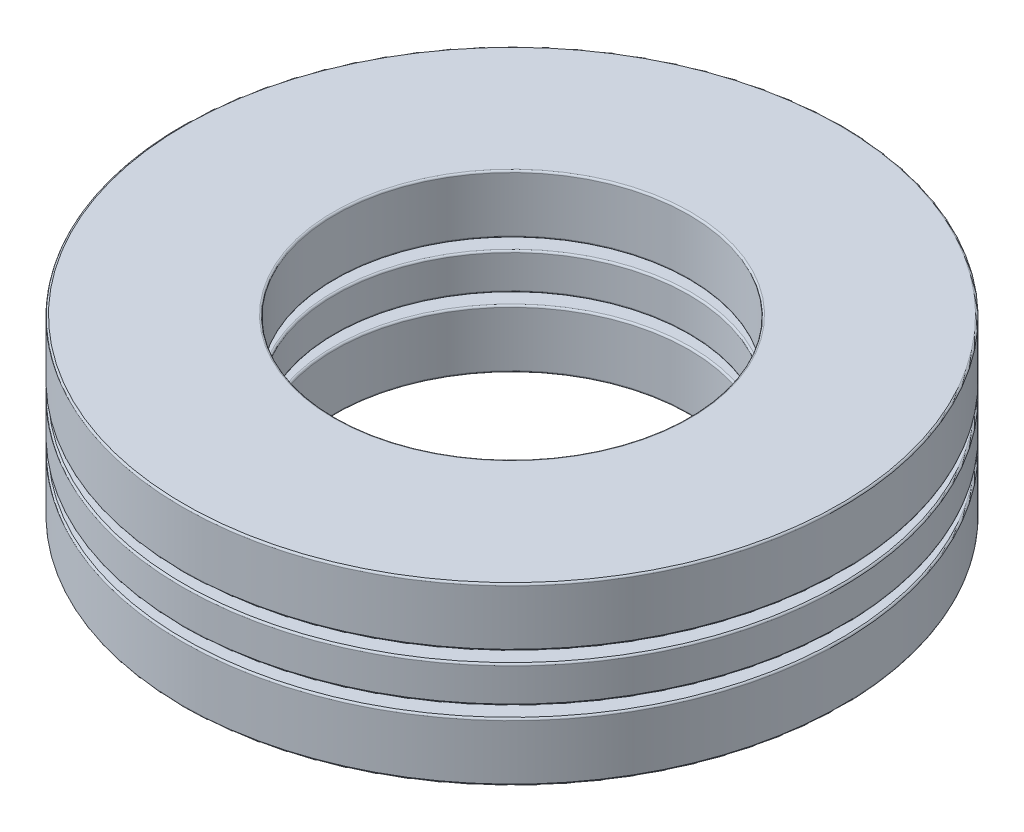
from build123d import *

# Parameters (mm, degrees)
SKETCH1_W         = 5.51815
SKETCH1_H         = 1.317625
CIRPATTERN1_COUNT = 5
CIRPATTERN1_ANGLE = 288
CIRPATTERN2_COUNT = 5
SKETCH4_W         = 5.51815
SKETCH4_H         = 2.1082
FILLET1_R         = 0.063246
FILLET2_R         = 0.063246
FILLET3_R         = 0.063246


with BuildPart() as part:
    # Sketch1 → Revolve1 (revolve)
    with BuildSketch(Plane(origin=(0, 0, 0), x_dir=(0, 0, -1), z_dir=(1, 0, 0))):
        with Locations((-9.147175, 0)):
            Rectangle(SKETCH1_W, SKETCH1_H)
    revolve(axis=Axis((0, -3.1623, 0), (0, 1, 0)))

    # Sketch3 → Cut-Revolve1 (revolve, cut)
    with BuildSketch(Plane(origin=(0, 0, 0), x_dir=(0, 0, -1), z_dir=(1, 0, 0))):
        with BuildLine():
            Line((-9.147175, 1.0541), (-9.147175, -1.0541))
            ThreePointArc((-9.147175, -1.0541), (-10.201275, 0), (-9.147175, 1.0541))
        make_face()
    cut_revolve1 = revolve(axis=Axis((0, 1.0541, 9.147175), (0, -1, 0)), mode=Mode.SUBTRACT)

    # CirPattern2: Cut-Revolve1 ×5 about axis
    cirpattern2_axis = Axis((0, 0, 0), (0, 1, 0))
    for i in range(1, CIRPATTERN2_COUNT):
        add(cut_revolve1.rotate(cirpattern2_axis, i * 360 / CIRPATTERN2_COUNT), mode=Mode.SUBTRACT)

    # Fillet2
    fillet2_edges = [part.edges().sort_by_distance(p)[0] for p in [
        (0, 0.6588125, -11.90625),
        (0, 0.6588125, -6.3881),
        (0, -0.6588125, -6.3881),
        (0, -0.6588125, -11.90625),
    ]]
    fillet(fillet2_edges, radius=FILLET2_R)


with BuildPart() as body_2:
    # Sketch2 → Revolve2 (revolve)
    with BuildSketch(Plane(origin=(0, 0, 0), x_dir=(0, 0, -1), z_dir=(1, 0, 0))):
        with BuildLine():
            Line((-9.147175, 1.0541), (-9.147175, -1.0541))
            ThreePointArc((-9.147175, -1.0541), (-10.201275, 0), (-9.147175, 1.0541))
        make_face()
    revolve(axis=Axis((0, 1.0541, 9.147175), (0, -1, 0)))


with BuildPart() as cirpattern1_1:
    # CirPattern1: pattern copy
    add(body_2.part.rotate(Axis((0, 3.1623, 0), (0, -1, 0)), 1 * CIRPATTERN1_ANGLE / (CIRPATTERN1_COUNT - 1)))


with BuildPart() as cirpattern1_2:
    # CirPattern1: pattern copy
    add(body_2.part.rotate(Axis((0, 3.1623, 0), (0, -1, 0)), 2 * CIRPATTERN1_ANGLE / (CIRPATTERN1_COUNT - 1)))


with BuildPart() as cirpattern1_3:
    # CirPattern1: pattern copy
    add(body_2.part.rotate(Axis((0, 3.1623, 0), (0, -1, 0)), 3 * CIRPATTERN1_ANGLE / (CIRPATTERN1_COUNT - 1)))


with BuildPart() as cirpattern1_4:
    # CirPattern1: pattern copy
    add(body_2.part.rotate(Axis((0, 3.1623, 0), (0, -1, 0)), 4 * CIRPATTERN1_ANGLE / (CIRPATTERN1_COUNT - 1)))


with BuildPart() as body_7:
    # Sketch4 → Revolve3 (revolve)
    with BuildSketch(Plane(origin=(0, 0, 0), x_dir=(0, 0, -1), z_dir=(1, 0, 0))):
        with Locations((-9.147175, 2.1082)):
            Rectangle(SKETCH4_W, SKETCH4_H)
        with Locations((-9.147175, -2.1082)):
            Rectangle(SKETCH4_W, SKETCH4_H)
    revolve(axis=Axis((0, -3.1623, 0), (0, 1, 0)))

    # Fillet1
    fillet1_edges = [body_7.edges().sort_by_distance(p)[0] for p in [
        (0, 1.0541, -11.90625),
        (0, 1.0541, -6.3881),
        (0, 3.1623, -6.3881),
        (0, 3.1623, -11.90625),
    ]]
    fillet(fillet1_edges, radius=FILLET1_R)

    # Fillet3
    fillet3_edges = [body_7.edges().sort_by_distance(p)[0] for p in [
        (0, -3.1623, -11.90625),
        (0, -3.1623, -6.3881),
        (0, -1.0541, -6.3881),
        (0, -1.0541, -11.90625),
    ]]
    fillet(fillet3_edges, radius=FILLET3_R)


solid = Compound([part.part, body_2.part, cirpattern1_1.part, cirpattern1_2.part, cirpattern1_3.part, cirpattern1_4.part, body_7.part])
